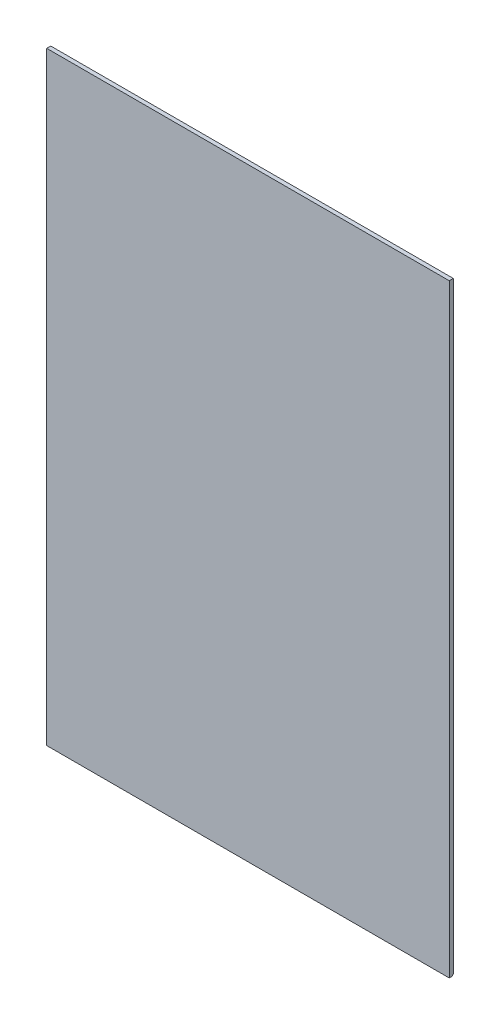
from build123d import *

# Parameters (mm, degrees)
ESQUISSE1_W        = 50
ESQUISSE1_H        = 75
BOSS_EXTRU_1_DEPTH = 0.5
CONG_1_R           = 0.25


with BuildPart() as part:
    # Esquisse1 → Boss.-Extru.1 (new body)
    with BuildSketch(Plane.XY):
        with Locations((25, 37.5)):
            Rectangle(ESQUISSE1_W, ESQUISSE1_H)
    extrude(amount=BOSS_EXTRU_1_DEPTH)

    # Congé1
    cong_1_edges = [part.edges().sort_by_distance(p)[0] for p in [
        (25, 0, 0),
    ]]
    fillet(cong_1_edges, radius=CONG_1_R)


solid = part.part
